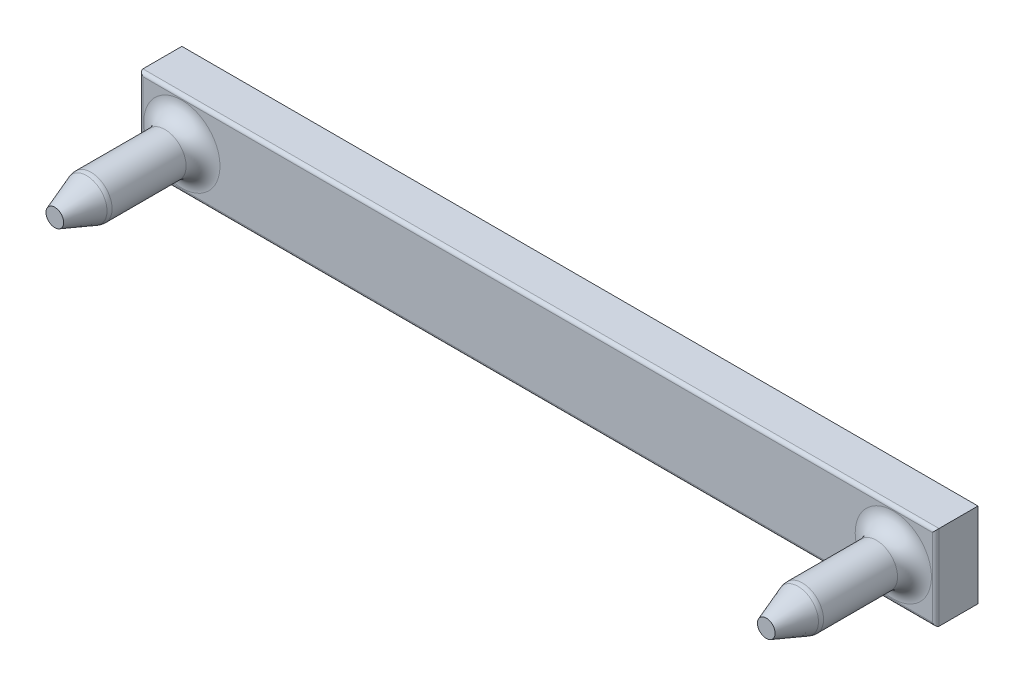
from build123d import *

# Parameters (mm, degrees)
SKETCH2_R             = 2.5
BOSS_EXTRUDE1_DEPTH   = 15
BOSS_EXTRUDE1_2_DEPTH = 15
SKETCH3_W             = 94
SKETCH3_H             = 10
BOSS_EXTRUDE2_DEPTH   = 5
FILLET1_R             = 2
FILLET2_R             = 0.4
CHAMFER1_SIZE         = 4
CHAMFER1_SIZE2        = 1.455880937
CHAMFER1_PART_2_SIZE  = 4
CHAMFER1_PART_2_SIZE2 = 1.455880937
FILLET4_R             = 1.5


with BuildPart() as part:
    # Sketch2 → Boss-Extrude1 (new body)
    with BuildSketch(Plane(origin=(0, 0, 0), x_dir=(0, 1, 0), z_dir=(0, 0, 1))):
        with Locations((8, 92)):
            Circle(SKETCH2_R)
    extrude(amount=-BOSS_EXTRUDE1_DEPTH)



with BuildPart() as body_2:
    # Sketch2 → Boss-Extrude1 2 (new body)
    with BuildSketch(Plane(origin=(0, 0, 0), x_dir=(0, 1, 0), z_dir=(0, 0, 1))):
        with Locations((8, 8)):
            Circle(SKETCH2_R)
    extrude(amount=-BOSS_EXTRUDE1_2_DEPTH)


with BuildPart() as part_1:
    add(part.part)

    add(body_2.part)  # Boss-Extrude2 merges body 2
    # Sketch3 → Boss-Extrude2 (add)
    with BuildSketch(Plane(origin=(0, 0, -15), x_dir=(1, 0, 0), z_dir=(0, 0, -1))):
        with Locations((-50, -8)):
            Rectangle(SKETCH3_W, SKETCH3_H)
    extrude(amount=BOSS_EXTRUDE2_DEPTH)

    # Fillet1
    fillet1_edges = [part_1.edges().sort_by_distance(p)[0] for p in [
        (-8, 5.5, -15),
        (-92, 5.5, -15),
    ]]
    fillet(fillet1_edges, radius=FILLET1_R)

    # Fillet2
    fillet2_edges = [part_1.edges().sort_by_distance(p)[0] for p in [
        (-97, 8, -15),
        (-50, 13, -15),
        (-3, 8, -15),
        (-50, 3, -15),
    ]]
    fillet(fillet2_edges, radius=FILLET2_R)

    # Chamfer1
    chamfer1_edges = [part_1.edges().sort_by_distance(p)[0] for p in [
        (-8, 5.5, 0),
    ]]
    chamfer1_side = [part_1.faces().sort_by_distance(p)[0] for p in [
        (-8, 5.5, -6.5),
    ]]
    chamfer(chamfer1_edges, length=CHAMFER1_SIZE, length2=CHAMFER1_SIZE2, reference=chamfer1_side[0])

    # Chamfer1 part 2
    chamfer1_part_2_edges = [part_1.edges().sort_by_distance(p)[0] for p in [
        (-92, 5.5, 0),
    ]]
    chamfer1_part_2_side = [part_1.faces().sort_by_distance(p)[0] for p in [
        (-92, 5.5, -6.5),
    ]]
    chamfer(chamfer1_part_2_edges, length=CHAMFER1_PART_2_SIZE, length2=CHAMFER1_PART_2_SIZE2, reference=chamfer1_part_2_side[0])

    # Fillet4
    fillet4_edges = [part_1.edges().sort_by_distance(p)[0] for p in [
        (-8, 5.5, -4),
        (-92, 5.5, -4),
    ]]
    fillet(fillet4_edges, radius=FILLET4_R)


solid = part_1.part
